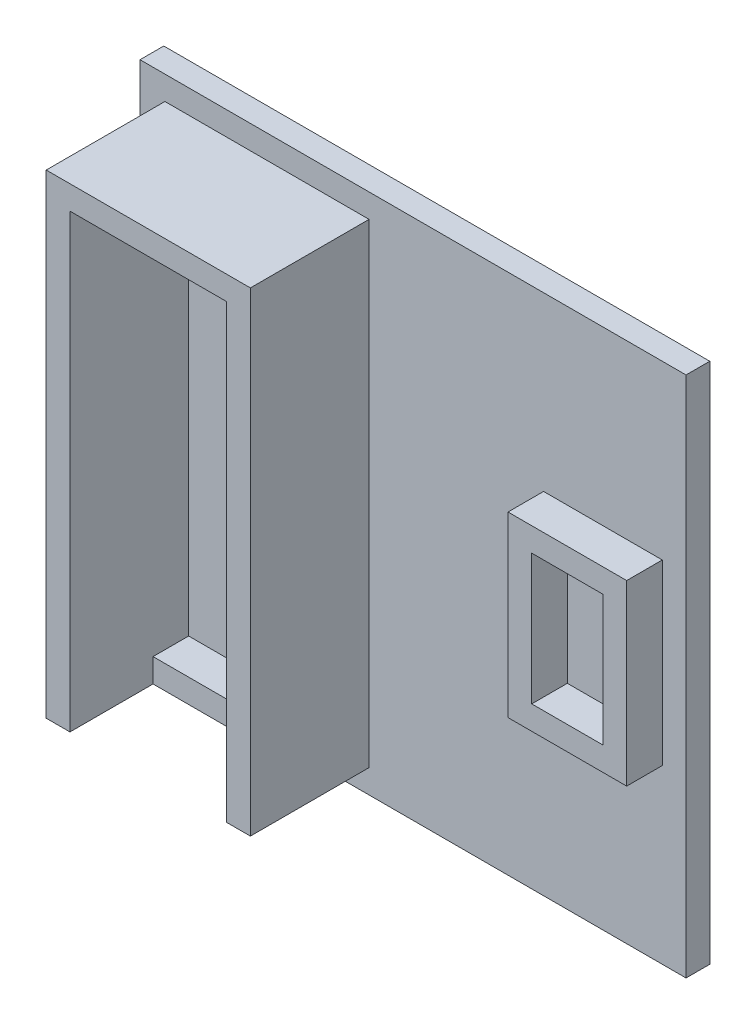
from build123d import *

# Parameters (mm, degrees)
ESQUISSE1_W        = 230
ESQUISSE1_H        = 220
BOSS_EXTRU_1_DEPTH = 10
BOSS_EXTRU_2_DEPTH = 50
ESQUISSE3_W        = 66
ESQUISSE3_H        = 10
BOSS_EXTRU_3_DEPTH = 15
ESQUISSE4_W        = 50
ESQUISSE4_H        = 75
ESQUISSE4_W_2      = 30
ESQUISSE4_H_2      = 55
BOSS_EXTRU_4_DEPTH = 15


with BuildPart() as part:
    # Esquisse1 → Boss.-Extru.1 (new body)
    with BuildSketch(Plane.XY):
        with Locations((115, 110)):
            Rectangle(ESQUISSE1_W, ESQUISSE1_H)
    extrude(amount=BOSS_EXTRU_1_DEPTH)

    # Esquisse2 → Boss.-Extru.2 (add)
    with BuildSketch(Plane.XY.offset(10)):
        Polygon((10.487156365, 10), (20.487156365, 10), (20.487156365, 200), (86.487156365, 200), (86.487156365, 10), (96.487156365, 10), (96.487156365, 210), (86.487156365, 210), (20.487156365, 210), (10.487156365, 210), align=None)
    extrude(amount=BOSS_EXTRU_2_DEPTH)

    # Esquisse3 → Boss.-Extru.3 (add)
    with BuildSketch(Plane.XY.offset(10)):
        with Locations((53.487156365, 15)):
            Rectangle(ESQUISSE3_W, ESQUISSE3_H)
    extrude(amount=BOSS_EXTRU_3_DEPTH)

    # Esquisse4 → Boss.-Extru.4 (add)
    with BuildSketch(Plane.XY.offset(10)):
        with Locations((195, 110)):
            Rectangle(ESQUISSE4_W, ESQUISSE4_H)
        with Locations((195, 110)):
            Rectangle(ESQUISSE4_W_2, ESQUISSE4_H_2, mode=Mode.SUBTRACT)
    extrude(amount=BOSS_EXTRU_4_DEPTH)


solid = part.part
